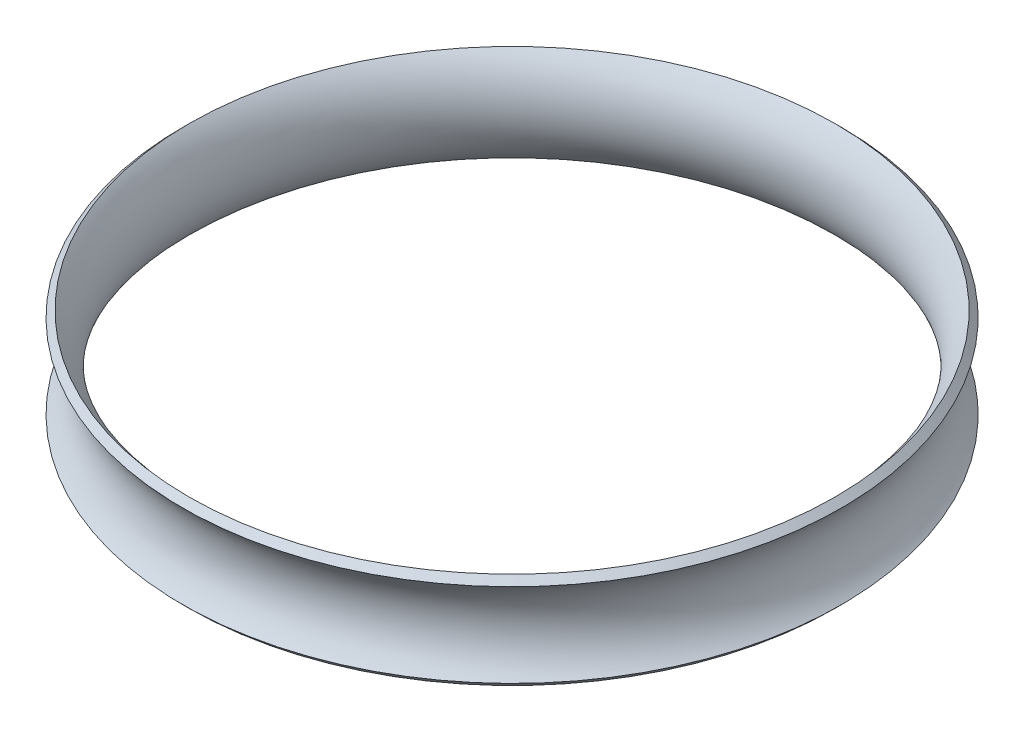
from build123d import *


with BuildPart() as part:
    # Sketch5 → Revolve-Thin1 (revolve)
    with BuildSketch(Plane.XY):
        with BuildLine():
            ThreePointArc((92.986360128, 23.622), (88.094083743, 11.811), (92.986360128, 0))
            Line((92.986360128, 0), (91.190308904, -1.796051224))
            ThreePointArc((91.190308904, -1.796051224), (85.554083743, 11.811), (91.190308904, 25.418051224))
            Line((91.190308904, 25.418051224), (92.986360128, 23.622))
        make_face()
    revolve(axis=Axis((0, 0, 0), (0, 1, 0)))


solid = part.part
